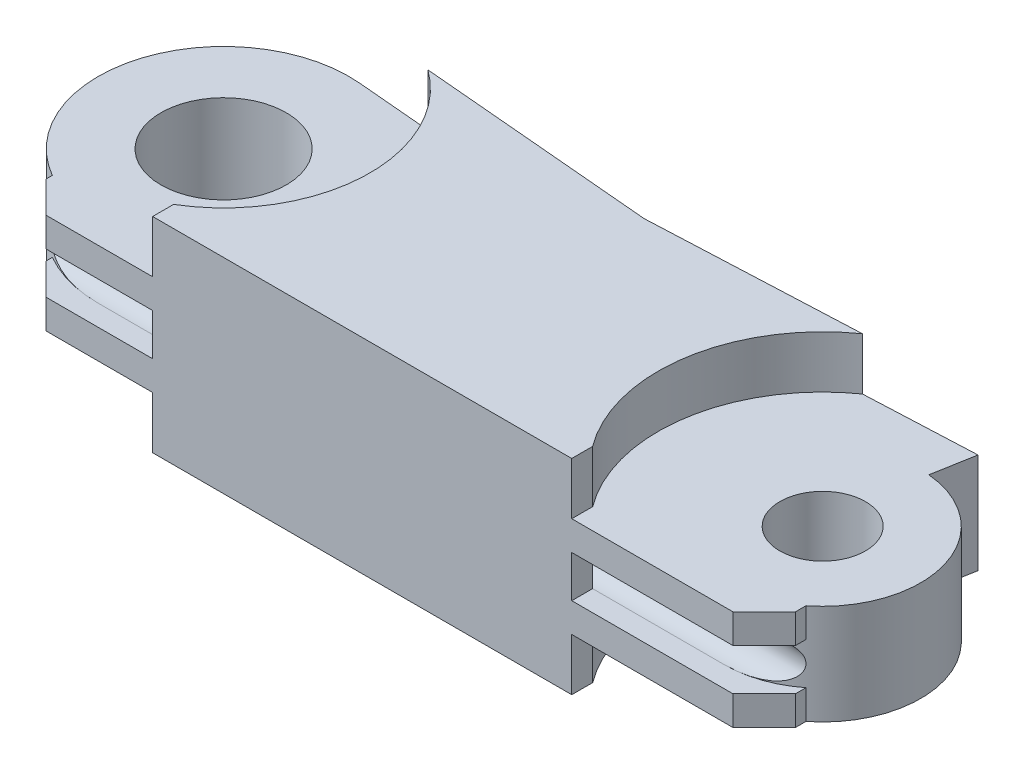
from build123d import *

# Parameters (mm, degrees)
BOSS_EXTRUDE1_DEPTH             = 2.4
BOSS_EXTRUDE1_DEPTH_BACK        = 2.4
SKETCH2_R                       = 2.05
SKETCH2_R_2                     = 3
BOSS_EXTRUDE3_DEPTH             = 2.5
BOSS_EXTRUDE4_REACH             = 39.46
SKETCH11_W                      = 20.072017009
SKETCH11_H                      = 1
CUT_EXTRUDE1_REACH              = 32.963
CUT_EXTRUDE1_DIRECTION_2_REACH  = 32.963
BOSS_EXTRUDE5_REACH             = 40.271
SKETCH14_W                      = 6.607136291
SKETCH14_H                      = 1.4
BOSS_EXTRUDE5_DIRECTION_2_REACH = 40.271
BOSS_EXTRUDE6_REACH             = 40.271
SKETCH16_W                      = 9.217702834
SKETCH16_H                      = 1.4
BOSS_EXTRUDE6_DIRECTION_2_REACH = 40.271
CHAMFER1_SIZE                   = 1.5
CHAMFER1_OF_MIRROR2_SIZE        = 1.5


with BuildPart() as part:
    # Sketch2 → Boss-Extrude1 (new, two sides: drawn at the far end of the back side and taken through both)
    with BuildSketch(Plane(origin=(0, 0, 0), x_dir=(1, 0, 0), z_dir=(0, 1, 0)).offset(-BOSS_EXTRUDE1_DEPTH_BACK)):
        with BuildLine():
            Line((-30, -4.695887824), (0, -4.695887824))
            ThreePointArc((0, -4.695887824), (4.691418379, -0.20483175), (0.409273591, 4.678018553))
            Line((0.409273591, 4.678018553), (0.761927553, 6.678018553))
            Line((0.761927553, 6.678018553), (-14.53364688, 5.985354694))
            Line((-14.53364688, 5.985354694), (-29.476567352, 7.292690835))
            ThreePointArc((-29.476567352, 7.292690835), (-36, 1.571793945), (-30, -4.695887824))
        make_face()
        Circle(SKETCH2_R, mode=Mode.SUBTRACT)
        with Locations((-30, 1.309828287)):
            Circle(SKETCH2_R_2, mode=Mode.SUBTRACT)
    extrude(amount=BOSS_EXTRUDE1_DEPTH + BOSS_EXTRUDE1_DEPTH_BACK)

    # Sketch10 → Boss-Extrude3 (add)
    with BuildSketch(Plane(origin=(0, 2.4, 0), x_dir=(1, 0, 0), z_dir=(0, 1, 0))):
        with BuildLine():
            ThreePointArc((-25.883157303, 6.978308193), (-23.000951778, 1.004243242), (-26.392863709, -4.695887824))
            Line((-26.392863709, -4.695887824), (-26.392863709, -5.695887824))
            Line((-26.392863709, -5.695887824), (-6.3208467, -5.695887824))
            Line((-6.3208467, -5.695887824), (-6.3208467, -4.695887824))
            ThreePointArc((-6.3208467, -4.695887824), (-7.774768517, 1.247974345), (-4.53364688, 6.438207159))
            Line((-4.53364688, 6.438207159), (-14.53364688, 5.985354694))
            Line((-14.53364688, 5.985354694), (-25.883157303, 6.978308193))
        make_face()
    boss_extrude3 = extrude(amount=BOSS_EXTRUDE3_DEPTH)

    # Mirror1: Boss-Extrude3 across plane
    add(boss_extrude3.mirror(Plane.ZX))

    # Sketch11 → Boss-Extrude4 (add, up to next)
    with BuildSketch(Plane.XZ.offset(-2.4), mode=Mode.PRIVATE) as boss_extrude4_sk1:
        with Locations((-16.356855205, 5.195887824)):
            Rectangle(SKETCH11_W, SKETCH11_H)
    boss_extrude4_tool1 = extrude(boss_extrude4_sk1.sketch, amount=BOSS_EXTRUDE4_REACH, mode=Mode.PRIVATE) - part.part
    add(boss_extrude4_tool1.solids().sort_by_distance((-16.356855, 2.4, 5.195888))[0])

    # Sketch13 → Cut-Extrude1 (cut, up to next)
    with BuildSketch(Plane(origin=(-6.3208467, 0, 0), x_dir=(0, 0, -1), z_dir=(1, 0, 0)), mode=Mode.PRIVATE) as cut_extrude1_sk1:
        with BuildLine():
            Line((-4.695887824, -1), (-4.695887824, 1))
            ThreePointArc((-4.695887824, 1), (-3.695887824, 0), (-4.695887824, -1))
        make_face()
    cut_extrude1_tool1 = extrude(cut_extrude1_sk1.sketch, amount=-CUT_EXTRUDE1_REACH, mode=Mode.PRIVATE) & part.part
    add(cut_extrude1_tool1.solids().sort_by_distance((-6.320847, 0, 4.271475))[0], mode=Mode.SUBTRACT)

    # Sketch13 → Cut-Extrude1 direction 2 (cut, up to next)
    with BuildSketch(Plane(origin=(-6.3208467, 0, 0), x_dir=(0, 0, -1), z_dir=(1, 0, 0)), mode=Mode.PRIVATE) as cut_extrude1_direction_2_sk1:
        with BuildLine():
            Line((-4.695887824, -1), (-4.695887824, 1))
            ThreePointArc((-4.695887824, 1), (-3.695887824, 0), (-4.695887824, -1))
        make_face()
    cut_extrude1_direction_2_tool1 = extrude(cut_extrude1_direction_2_sk1.sketch, amount=CUT_EXTRUDE1_DIRECTION_2_REACH, mode=Mode.PRIVATE) & part.part
    add(cut_extrude1_direction_2_tool1.solids().sort_by_distance((-6.320847, 0, 4.271475))[0], mode=Mode.SUBTRACT)

    # Boss-Extrude5: up to this face of the body (flat: up to its plane)
    boss_extrude5_end = Plane(part.part.faces().sort_by_distance((-16.356855205, 0, 5.695887824))[0])
    # Sketch14 → Boss-Extrude5 (add, up to the picked face)
    with BuildSketch(Plane.XY.offset(4.695887824), mode=Mode.PRIVATE) as boss_extrude5_sk1:
        with Locations((-29.696431854, -1.7)):
            Rectangle(SKETCH14_W, SKETCH14_H)
    boss_extrude5_tool1 = split(extrude(boss_extrude5_sk1.sketch, amount=BOSS_EXTRUDE5_REACH, mode=Mode.PRIVATE), bisect_by=boss_extrude5_end, keep=Keep.BOTH, mode=Mode.PRIVATE)
    boss_extrude5 = boss_extrude5_tool1.solids().sort_by(Axis((-29.696432, -1.7, 4.695888), (0, 0, 1)))[0]
    add(boss_extrude5)

    # Sketch14 → Boss-Extrude5 direction 2 (add, up to next)
    with BuildSketch(Plane.XY.offset(4.695887824), mode=Mode.PRIVATE) as boss_extrude5_direction_2_sk1:
        with Locations((-29.696431854, -1.7)):
            Rectangle(SKETCH14_W, SKETCH14_H)
    boss_extrude5_direction_2_tool1 = extrude(boss_extrude5_direction_2_sk1.sketch, amount=-BOSS_EXTRUDE5_DIRECTION_2_REACH, mode=Mode.PRIVATE) - part.part
    boss_extrude5_direction_2 = boss_extrude5_direction_2_tool1.solids().sort_by_distance((-29.696432, -1.7, 4.695888))[0]
    add(boss_extrude5_direction_2)

    # Boss-Extrude6: up to this face of the body (flat: up to its plane)
    boss_extrude6_end = Plane(part.part.faces().sort_by_distance((-16.955969125, -0.076351274, 5.695887824))[0])
    # Sketch16 → Boss-Extrude6 (add, up to the picked face)
    with BuildSketch(Plane.XY.offset(4.695887824), mode=Mode.PRIVATE) as boss_extrude6_sk1:
        with Locations((-1.711995283, -1.7)):
            Rectangle(SKETCH16_W, SKETCH16_H)
    boss_extrude6_tool1 = split(extrude(boss_extrude6_sk1.sketch, amount=BOSS_EXTRUDE6_REACH, mode=Mode.PRIVATE), bisect_by=boss_extrude6_end, keep=Keep.BOTH, mode=Mode.PRIVATE)
    boss_extrude6 = boss_extrude6_tool1.solids().sort_by(Axis((-1.711995, -1.7, 4.695888), (0, 0, 1)))[0]
    add(boss_extrude6)

    # Sketch16 → Boss-Extrude6 direction 2 (add, up to next)
    with BuildSketch(Plane.XY.offset(4.695887824), mode=Mode.PRIVATE) as boss_extrude6_direction_2_sk1:
        with Locations((-1.711995283, -1.7)):
            Rectangle(SKETCH16_W, SKETCH16_H)
    boss_extrude6_direction_2_tool1 = extrude(boss_extrude6_direction_2_sk1.sketch, amount=-BOSS_EXTRUDE6_DIRECTION_2_REACH, mode=Mode.PRIVATE) - part.part
    boss_extrude6_direction_2 = boss_extrude6_direction_2_tool1.solids().sort_by_distance((-1.711995, -1.7, 4.695888))[0]
    add(boss_extrude6_direction_2)

    # Chamfer1
    chamfer1_edges = [part.edges().sort_by_distance(p)[0] for p in [
        (-33, -1.7, 5.695887824),
        (2.896856134, -1.7, 5.695887824),
    ]]
    chamfer(chamfer1_edges, length=CHAMFER1_SIZE)

    # Mirror2: Boss-Extrude5, Boss-Extrude5 direction 2, Boss-Extrude6, Boss-Extrude6 direction 2 across plane
    add(boss_extrude5.mirror(Plane.ZX))
    add(boss_extrude5_direction_2.mirror(Plane.ZX))
    add(boss_extrude6.mirror(Plane.ZX))
    add(boss_extrude6_direction_2.mirror(Plane.ZX))

    # Chamfer1 of Mirror2
    chamfer1_of_mirror2_edges = [part.edges().sort_by_distance(p)[0] for p in [
        (-33, 1.7, 5.695887824),
        (2.896856134, 1.7, 5.695887824),
    ]]
    chamfer(chamfer1_of_mirror2_edges, length=CHAMFER1_OF_MIRROR2_SIZE)


solid = part.part
